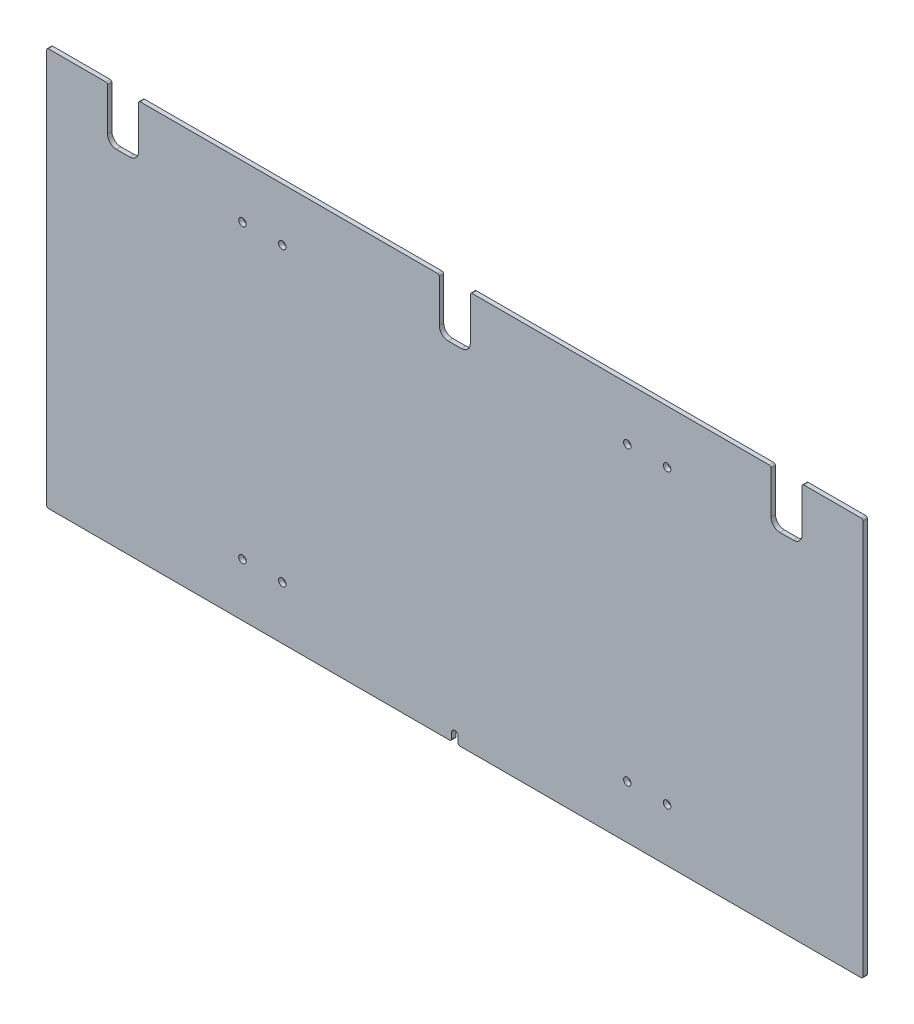
from build123d import *

# Parameters (mm, degrees)
SKETCH1_W                        = 1171.575
SKETCH1_H                        = 571.5
BOSS_EXTRUDE1_DEPTH              = 6.35
F_27_64_0_42188_DIAMETER_HOLE1_D = 10.715752
SKETCH5_W                        = 44.45
SKETCH5_H                        = 76.2
CUT_EXTRUDE1_DEPTH               = 7.35
CUT_EXTRUDE2_DEPTH               = 7.35
FILLET1_R                        = 12.7
FILLET2_R                        = 2.54


with BuildPart() as part:
    # Sketch1 → Boss-Extrude1 (new body)
    with BuildSketch(Plane.XY):
        with Locations((0, 285.75)):
            Rectangle(SKETCH1_W, SKETCH1_H)
    extrude(amount=BOSS_EXTRUDE1_DEPTH)

    # 27/64 (0.42188) Diameter Hole1 (through all)
    with Locations(Plane.XY.offset(6.35)):
        with Locations((304.8, 495.3), (-247.65, 495.3), (-304.8, 495.3), (-247.65, 76.2), (-304.8, 76.2), (247.65, 76.2), (304.8, 76.2), (247.65, 495.3)):
            Hole(F_27_64_0_42188_DIAMETER_HOLE1_D / 2)

    # Sketch5 → Cut-Extrude1 (cut, through all)
    with BuildSketch(Plane.XY.offset(6.35)):
        with Locations((-476.25, 533.4)):
            Rectangle(SKETCH5_W, SKETCH5_H)
        with Locations((0, 533.4)):
            Rectangle(SKETCH5_W, SKETCH5_H)
        with Locations((476.25, 533.4)):
            Rectangle(SKETCH5_W, SKETCH5_H)
    extrude(amount=-CUT_EXTRUDE1_DEPTH, mode=Mode.SUBTRACT)

    # Sketch6 → Cut-Extrude2 (cut, through all)
    with BuildSketch(Plane.XY.offset(6.35)):
        with BuildLine():
            Line((4.7625, 0), (-4.7625, 0))
            Line((-4.7625, 0), (-4.7625, 11.1125))
            ThreePointArc((-4.7625, 11.1125), (0, 15.875), (4.7625, 11.1125))
            Line((4.7625, 11.1125), (4.7625, 0))
        make_face()
    extrude(amount=-CUT_EXTRUDE2_DEPTH, mode=Mode.SUBTRACT)

    # Fillet1
    fillet1_edges = [part.edges().sort_by_distance(p)[0] for p in [
        (-454.025, 495.3, 3.175),
        (-498.475, 495.3, 3.175),
        (-22.225, 495.3, 3.175),
        (22.225, 495.3, 3.175),
        (454.025, 495.3, 3.175),
        (498.475, 495.3, 3.175),
    ]]
    fillet(fillet1_edges, radius=FILLET1_R)

    # Fillet2
    fillet2_edges = [part.edges().sort_by_distance(p)[0] for p in [
        (4.7625, 0, 3.175),
        (-4.7625, 0, 3.175),
        (-498.475, 571.5, 3.175),
        (-454.025, 571.5, 3.175),
        (-585.7875, 571.5, 3.175),
        (585.7875, 571.5, 3.175),
        (585.7875, 0, 3.175),
        (-22.225, 571.5, 3.175),
        (-585.7875, 0, 3.175),
        (22.225, 571.5, 3.175),
        (454.025, 571.5, 3.175),
        (498.475, 571.5, 3.175),
    ]]
    fillet(fillet2_edges, radius=FILLET2_R)


solid = part.part
